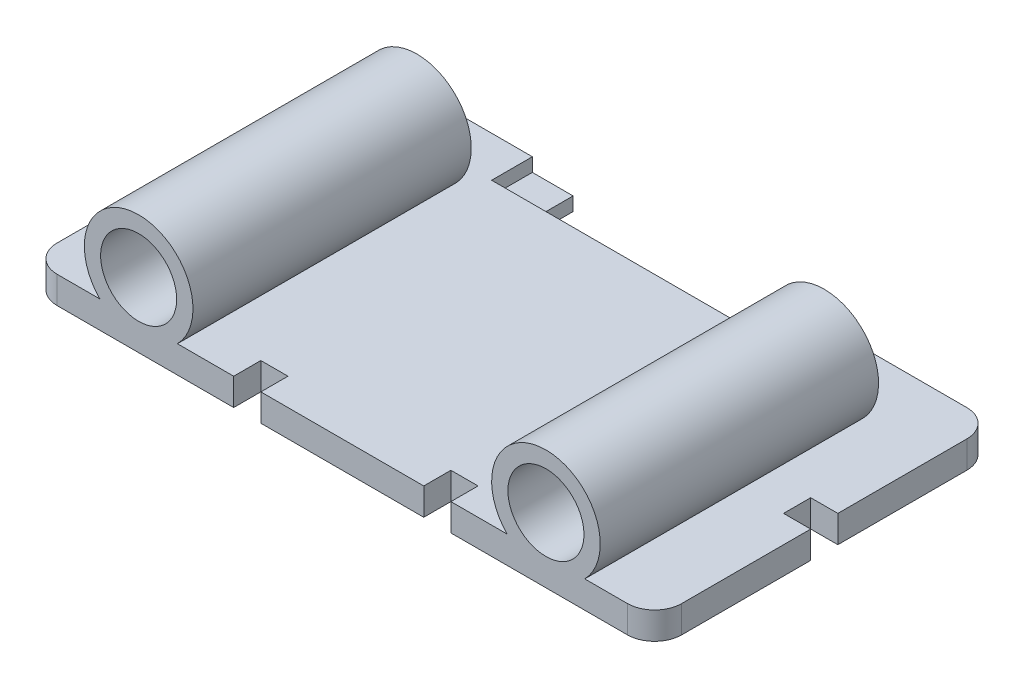
from build123d import *

# Parameters (mm, degrees)
SKETCH1_W           = 58.42
SKETCH1_H           = 31.75
BOSS_EXTRUDE1_DEPTH = 2.54
FILLET1_R           = 2.54
SKETCH4_R           = 5.08
BOSS_EXTRUDE3_DEPTH = 15.875
SKETCH5_R           = 5.08
BOSS_EXTRUDE4_DEPTH = 10.16
SKETCH6_R           = 3.556
CUT_EXTRUDE2_DEPTH  = 32.75
SKETCH9_W           = 13.97
SKETCH9_H           = 3.81
CUT_EXTRUDE4_DEPTH  = 1.27
SKETCH10_W          = 2.54
SKETCH10_H          = 2.54
SKETCH10_W_2        = 20.32
SKETCH10_H_2        = 3.81
CUT_EXTRUDE6_DEPTH  = 12.176


with BuildPart() as part:
    # Sketch1 → Boss-Extrude1 (new body)
    with BuildSketch(Plane(origin=(0, 0, 0), x_dir=(1, 0, 0), z_dir=(0, 1, 0))):
        Rectangle(SKETCH1_W, SKETCH1_H)
    extrude(amount=BOSS_EXTRUDE1_DEPTH)

    # Fillet1
    fillet1_edges = [part.edges().sort_by_distance(p)[0] for p in [
        (29.21, 1.27, 15.875),
        (-29.21, 1.27, 15.875),
        (-29.21, 1.27, -15.875),
        (29.21, 1.27, -15.875),
    ]]
    fillet(fillet1_edges, radius=FILLET1_R)

    # Sketch4 → Boss-Extrude3 (add)
    with BuildSketch(Plane.XY):
        with Locations((-19.05, 6.096)):
            Circle(SKETCH4_R)
        with Locations((19.05, 6.096)):
            Circle(SKETCH4_R)
    extrude(amount=BOSS_EXTRUDE3_DEPTH)

    # Sketch5 → Boss-Extrude4 (add)
    with BuildSketch(Plane(origin=(0, 0, 0), x_dir=(-1, 0, 0), z_dir=(0, 0, -1))):
        with Locations((-19.05, 6.096)):
            Circle(SKETCH5_R)
        with Locations((19.05, 6.096)):
            Circle(SKETCH5_R)
    extrude(amount=BOSS_EXTRUDE4_DEPTH)

    # Sketch6 → Cut-Extrude2 (cut, through all)
    with BuildSketch(Plane.XY.offset(15.875)):
        with Locations((-19.05, 6.096)):
            Circle(SKETCH6_R)
        with Locations((19.05, 6.096)):
            Circle(SKETCH6_R)
    extrude(amount=-CUT_EXTRUDE2_DEPTH, mode=Mode.SUBTRACT)

    # Sketch9 → Cut-Extrude4 (cut)
    with BuildSketch(Plane(origin=(0, 2.54, 0), x_dir=(1, 0, 0), z_dir=(0, 1, 0))):
        with Locations((-6.985, 13.97)):
            Rectangle(SKETCH9_W, SKETCH9_H)
        with Locations((6.985, 13.97)):
            Rectangle(SKETCH9_W, SKETCH9_H)
    extrude(amount=-CUT_EXTRUDE4_DEPTH, mode=Mode.SUBTRACT)

    # Sketch10 → Cut-Extrude6 (cut, through all)
    with BuildSketch(Plane(origin=(0, 0, 0), x_dir=(1, 0, 0), z_dir=(0, 1, 0))):
        with Locations((-27.94, 0)):
            Rectangle(SKETCH10_W, SKETCH10_H)
        with Locations((27.94, 0)):
            Rectangle(SKETCH10_W, SKETCH10_H)
        with Locations((0, 13.97)):
            Rectangle(SKETCH10_W_2, SKETCH10_H_2)
        with Locations((-8.89, -14.605)):
            Rectangle(SKETCH10_W, SKETCH10_H)
        with Locations((8.89, -14.605)):
            Rectangle(SKETCH10_W, SKETCH10_H)
    extrude(amount=CUT_EXTRUDE6_DEPTH, mode=Mode.SUBTRACT)


solid = part.part
